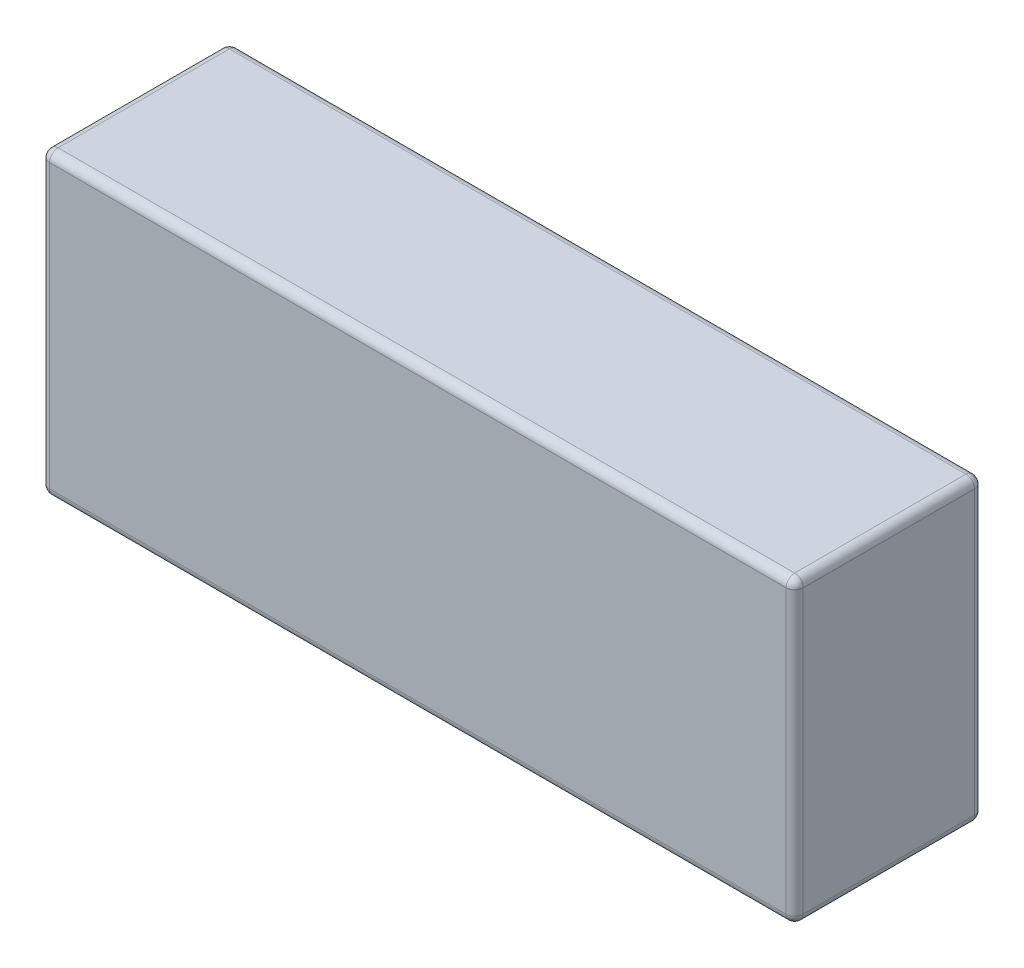
from build123d import *

# Parameters (mm, degrees)
SKETCH1_W           = 88
SKETCH1_H           = 22
BOSS_EXTRUDE1_DEPTH = 35
FILLET1_R           = 1


with BuildPart() as part:
    # Sketch1 → Boss-Extrude1 (new body)
    with BuildSketch(Plane(origin=(0, 0, 0), x_dir=(1, 0, 0), z_dir=(0, 1, 0))):
        Rectangle(SKETCH1_W, SKETCH1_H)
    extrude(amount=BOSS_EXTRUDE1_DEPTH)

    # Fillet1
    fillet1_edges = [part.edges().sort_by_distance(p)[0] for p in [
        (-44, 35, 0),
        (0, 35, 11),
        (44, 35, 0),
        (0, 0, 11),
        (-44, 0, 0),
        (0, 0, -11),
        (44, 0, 0),
        (0, 35, -11),
        (44, 17.5, 11),
        (-44, 17.5, 11),
        (-44, 17.5, -11),
        (44, 17.5, -11),
    ]]
    fillet(fillet1_edges, radius=FILLET1_R)


solid = part.part
